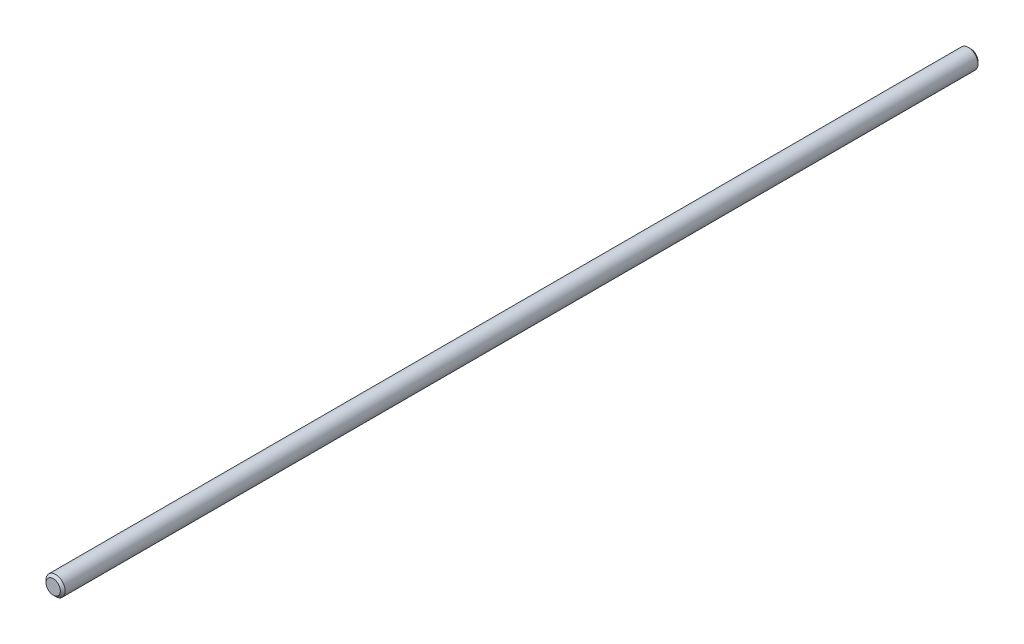
from build123d import *

# Parameters (mm, degrees)
SKETCH1_R           = 3.96875
BOSS_EXTRUDE1_DEPTH = 380
CHAMFER2_SIZE       = 1
CHAMFER3_SIZE       = 1


with BuildPart() as part:
    # Sketch1 → Boss-Extrude1 (new body)
    with BuildSketch(Plane.XY):
        Circle(SKETCH1_R)
    extrude(amount=BOSS_EXTRUDE1_DEPTH)

    # Chamfer2
    chamfer2_edges = [part.edges().sort_by_distance(p)[0] for p in [
        (-3.96875, 0, 0),
    ]]
    chamfer(chamfer2_edges, length=CHAMFER2_SIZE)

    # Chamfer3
    chamfer3_edges = [part.edges().sort_by_distance(p)[0] for p in [
        (-3.96875, 0, 380),
    ]]
    chamfer(chamfer3_edges, length=CHAMFER3_SIZE)


solid = part.part
